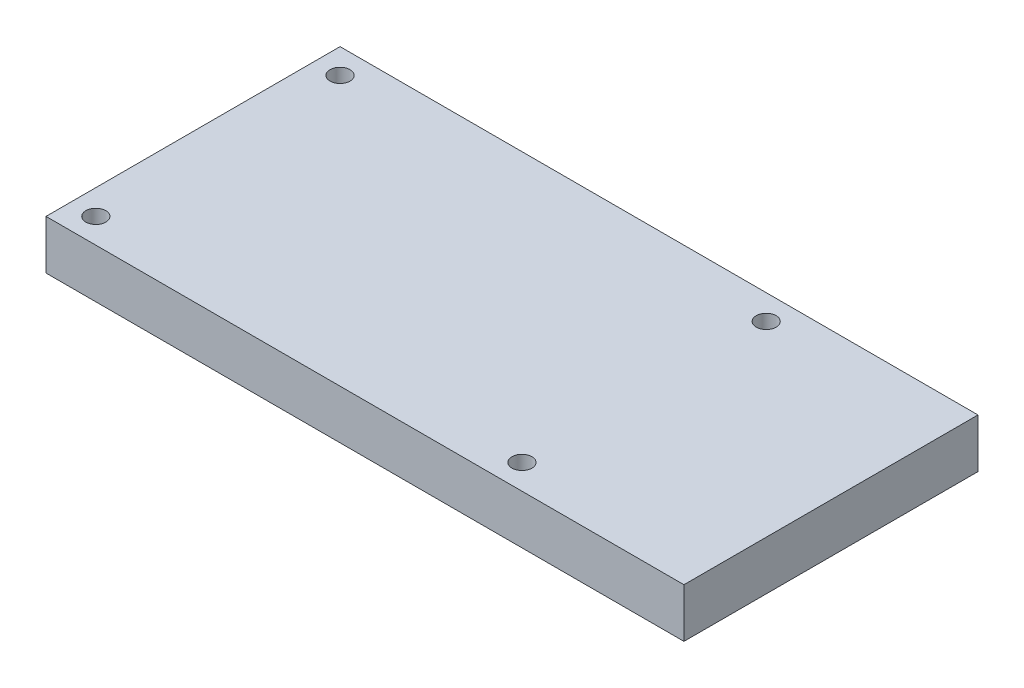
from build123d import *

# Parameters (mm, degrees)
SKETCH1_W           = 65.024
SKETCH1_H           = 29.972
SKETCH1_R           = 1.016
BOSS_EXTRUDE1_DEPTH = 5.0038


with BuildPart() as part:
    # Sketch1 → Boss-Extrude1 (new body)
    with BuildSketch(Plane(origin=(0, 0, 0), x_dir=(1, 0, 0), z_dir=(0, 1, 0))):
        Rectangle(SKETCH1_W, SKETCH1_H)
        with Locations((-29.972, 12.446)):
            Circle(SKETCH1_R, mode=Mode.SUBTRACT)
        with Locations((-29.972, -12.446)):
            Circle(SKETCH1_R, mode=Mode.SUBTRACT)
        with Locations((13.462, 12.446)):
            Circle(SKETCH1_R, mode=Mode.SUBTRACT)
        with Locations((13.462, -12.446)):
            Circle(SKETCH1_R, mode=Mode.SUBTRACT)
    extrude(amount=BOSS_EXTRUDE1_DEPTH)


solid = part.part
